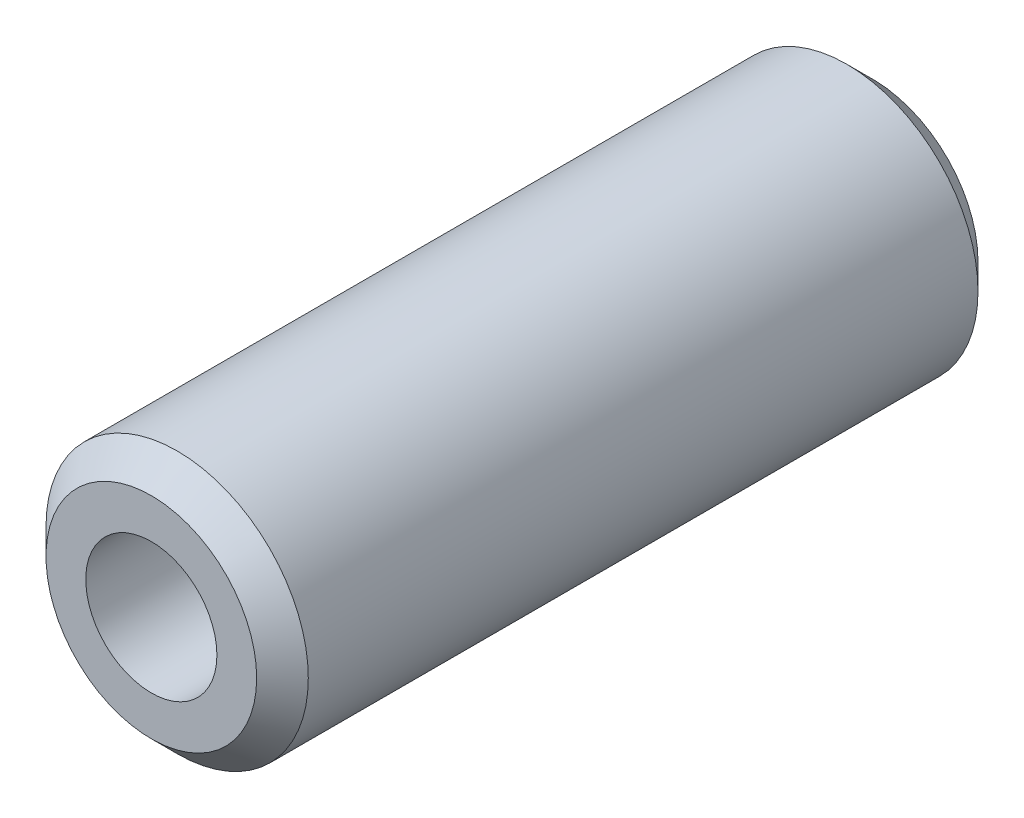
from build123d import *

# Parameters (mm, degrees)
ESQUISSE1_R        = 12.7
ESQUISSE1_R_2      = 6.35
BOSS_EXTRU_1_DEPTH = 34.925
CHANFREIN1_SIZE    = 2.5


with BuildPart() as part:
    # Esquisse1 → Boss.-Extru.1 (new body, symmetric)
    with BuildSketch(Plane.XY):
        Circle(ESQUISSE1_R)
        Circle(ESQUISSE1_R_2, mode=Mode.SUBTRACT)
    extrude(amount=BOSS_EXTRU_1_DEPTH, both=True)

    # Chanfrein1
    chanfrein1_edges = [part.edges().sort_by_distance(p)[0] for p in [
        (-12.7, 0, -34.925),
        (-12.7, 0, 34.925),
    ]]
    chamfer(chanfrein1_edges, length=CHANFREIN1_SIZE)


solid = part.part
